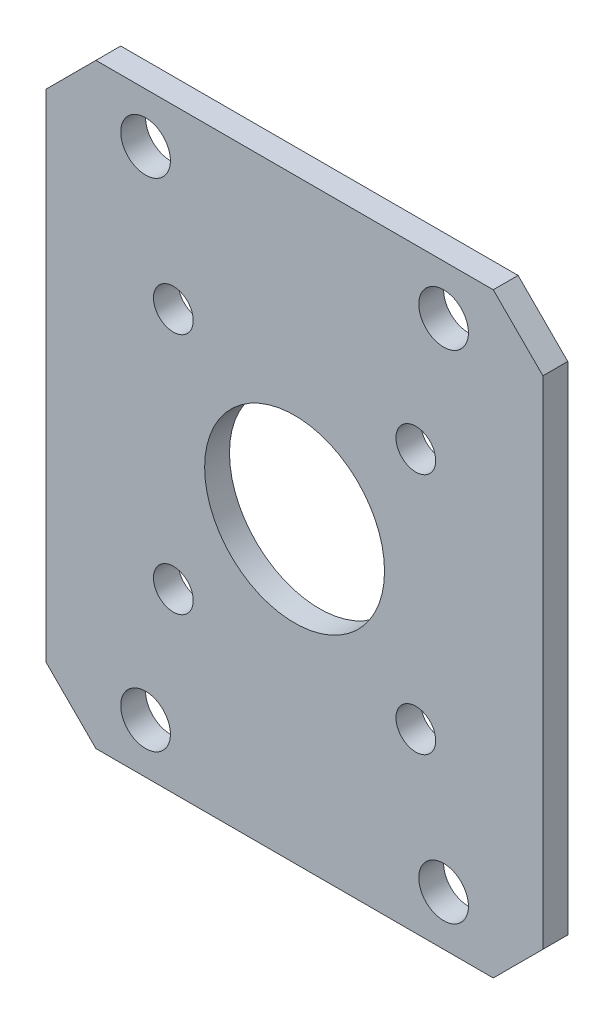
from build123d import *

# Parameters (mm, degrees)
SKETCH1_W           = 63.5
SKETCH1_H           = 76.2
BOSS_EXTRUDE1_DEPTH = 1.5875
SKETCH2_R           = 3.175
CUT_EXTRUDE1_DEPTH  = 4.175
SKETCH3_R           = 2.54
CUT_EXTRUDE2_DEPTH  = 4.175
CHAMFER1_SIZE       = 6.35
SKETCH4_R           = 11.5
CUT_EXTRUDE3_DEPTH  = 4.175


with BuildPart() as part:
    # Sketch1 → Boss-Extrude1 (new body, symmetric)
    with BuildSketch(Plane.XY):
        Rectangle(SKETCH1_W, SKETCH1_H)
    extrude(amount=BOSS_EXTRUDE1_DEPTH, both=True)

    # Sketch2 → Cut-Extrude1 (cut, through all)
    with BuildSketch(Plane.XY.offset(1.5875)):
        with Locations((-19.05, 31.75)):
            Circle(SKETCH2_R)
        with Locations((19.05, 31.75)):
            Circle(SKETCH2_R)
        with Locations((19.05, -31.75)):
            Circle(SKETCH2_R)
        with Locations((-19.05, -31.75)):
            Circle(SKETCH2_R)
    extrude(amount=-CUT_EXTRUDE1_DEPTH, mode=Mode.SUBTRACT)

    # Sketch3 → Cut-Extrude2 (cut, through all)
    with BuildSketch(Plane.XY.offset(1.5875)):
        with Locations((-15.5, 15.5)):
            Circle(SKETCH3_R)
        with Locations((15.5, 15.5)):
            Circle(SKETCH3_R)
        with Locations((15.5, -15.5)):
            Circle(SKETCH3_R)
        with Locations((-15.5, -15.5)):
            Circle(SKETCH3_R)
    extrude(amount=-CUT_EXTRUDE2_DEPTH, mode=Mode.SUBTRACT)

    # Chamfer1
    chamfer1_edges = [part.edges().sort_by_distance(p)[0] for p in [
        (31.75, -38.1, 0),
        (-31.75, -38.1, 0),
        (-31.75, 38.1, 0),
        (31.75, 38.1, 0),
    ]]
    chamfer(chamfer1_edges, length=CHAMFER1_SIZE)

    # Sketch4 → Cut-Extrude3 (cut, through all)
    with BuildSketch(Plane.XY.offset(1.5875)):
        Circle(SKETCH4_R)
    extrude(amount=-CUT_EXTRUDE3_DEPTH, mode=Mode.SUBTRACT)


solid = part.part
